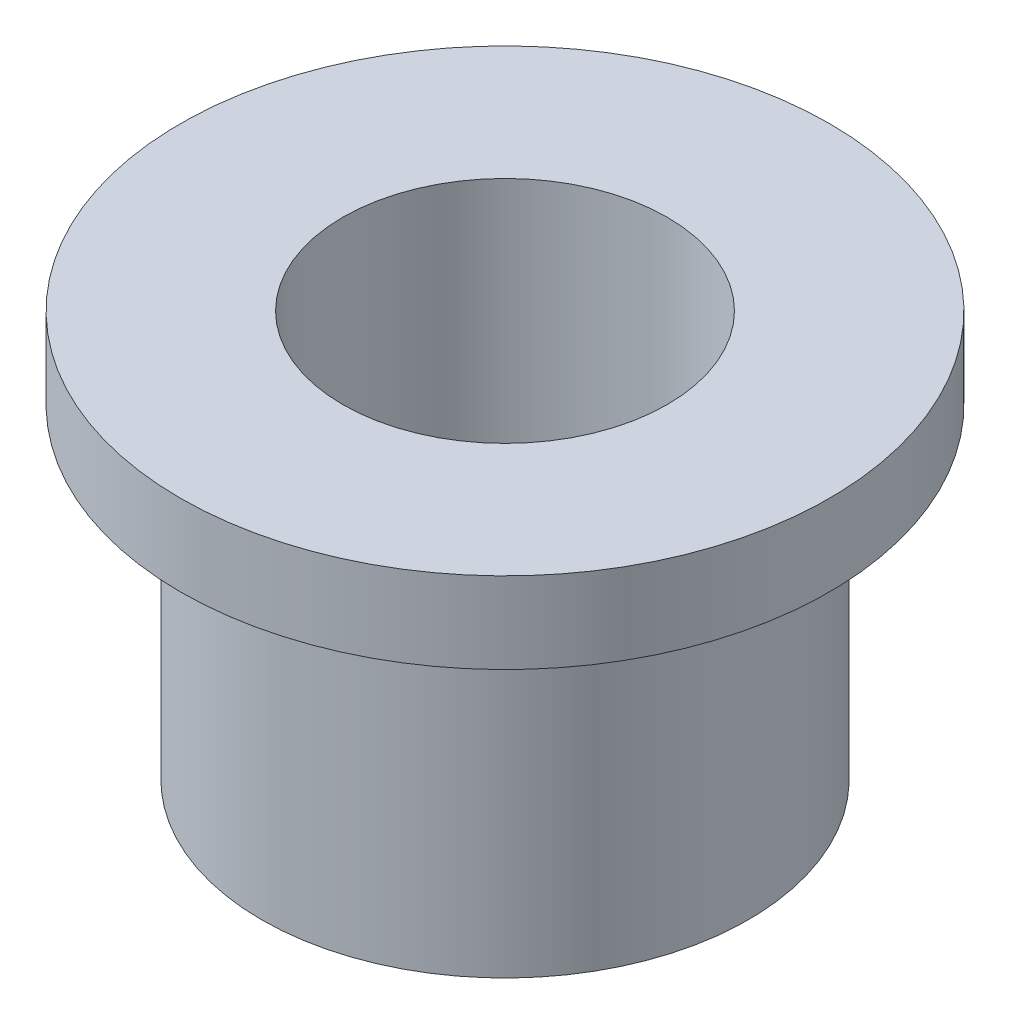
from build123d import *


with BuildPart() as part:
    # Sketch1 → Revolve1 (revolve)
    with BuildSketch(Plane.XY):
        Polygon((-50, 0), (-50, 125), (-100, 125), (-100, 100), (-75, 100), (-75, 0), align=None)
    revolve(axis=Axis((0, 167.383783148, 0), (0, -1, 0)))


solid = part.part
